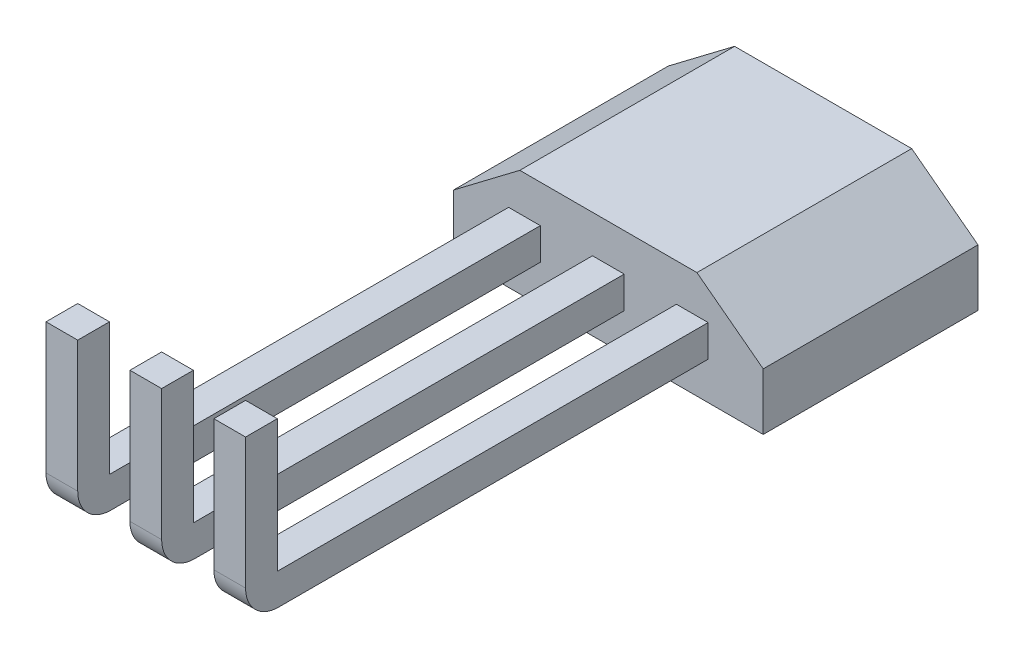
from build123d import *

# Parameters (mm, degrees)
SALIENTE_EXTRUIR1_DEPTH = 3.25
CROQUIS3_W              = 0.48
CROQUIS3_H              = 0.48
SALIENTE_EXTRUIR2_DEPTH = 7
CROQUIS4_W              = 0.48
CROQUIS4_H              = 0.48
SALIENTE_EXTRUIR3_DEPTH = 2
REDONDEO1_R             = 0.5


with BuildPart() as part:
    # Croquis2 → Saliente-Extruir1 (new body)
    with BuildSketch(Plane.XY):
        Polygon((-2.343416672, 0), (2.343416672, 0), (2.343416672, 0.86), (1.34, 1.62), (-1.34, 1.62), (-2.343416672, 0.86), align=None)
    extrude(amount=SALIENTE_EXTRUIR1_DEPTH)

    # Croquis3 → Saliente-Extruir2 (add)
    with BuildSketch(Plane.XY.offset(3.25)):
        with Locations((0, 0.81)):
            Rectangle(CROQUIS3_W, CROQUIS3_H)
        with Locations((1.27, 0.81)):
            Rectangle(CROQUIS3_W, CROQUIS3_H)
        with Locations((-1.27, 0.81)):
            Rectangle(CROQUIS3_W, CROQUIS3_H)
    extrude(amount=SALIENTE_EXTRUIR2_DEPTH)

    # Croquis4 → Saliente-Extruir3 (add)
    with BuildSketch(Plane(origin=(0, 1.05, 0), x_dir=(1, 0, 0), z_dir=(0, 1, 0))):
        with Locations((-1.27, -10.01)):
            Rectangle(CROQUIS4_W, CROQUIS4_H)
        with Locations((0, -10.01)):
            Rectangle(CROQUIS4_W, CROQUIS4_H)
        with Locations((1.27, -10.01)):
            Rectangle(CROQUIS4_W, CROQUIS4_H)
    extrude(amount=SALIENTE_EXTRUIR3_DEPTH)

    # Redondeo1
    redondeo1_edges = [part.edges().sort_by_distance(p)[0] for p in [
        (0, 0.57, 10.25),
        (1.27, 0.57, 10.25),
        (-1.27, 0.57, 10.25),
    ]]
    fillet(redondeo1_edges, radius=REDONDEO1_R)


solid = part.part
